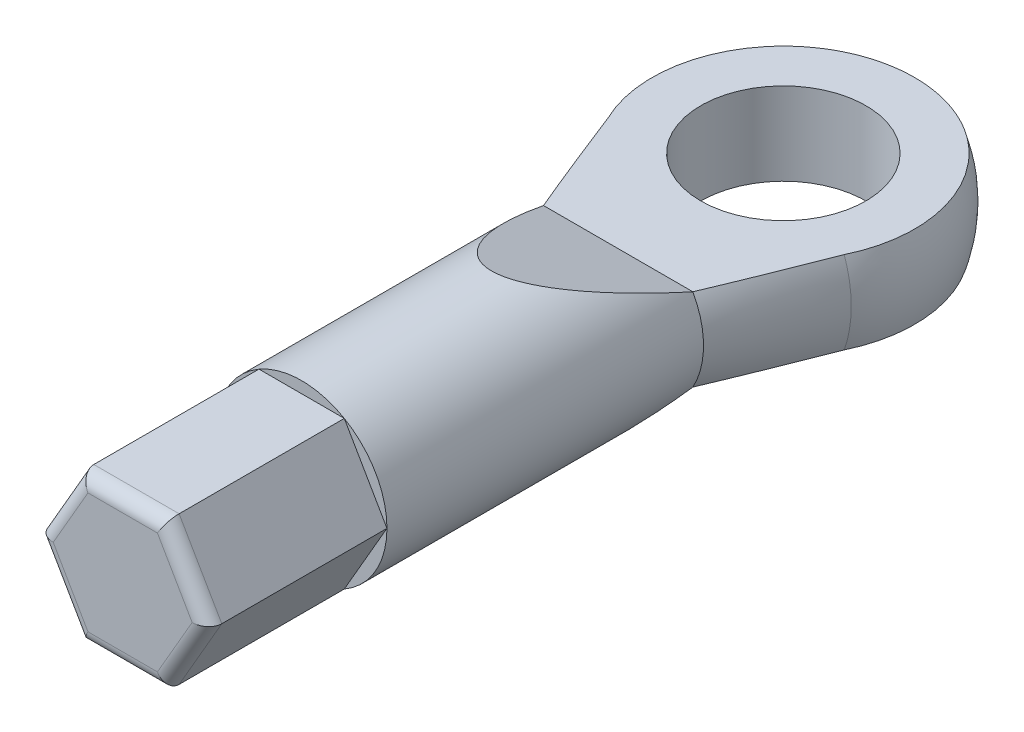
from build123d import *

# Parameters (mm, degrees)
CUT_EXTRUDE2_DEPTH = 6
SKETCH4_OUTSIDE_W  = 18.26
SKETCH4_OUTSIDE_H  = 14.46
CUT_EXTRUDE3_DEPTH = 6.5
FILLET1_R          = 0.5
CUT_EXTRUDE4_START = -1.5
SKETCH5_R          = 3
CUT_EXTRUDE4_DEPTH = 1.5


with BuildPart() as part:
    # Sketch1 → Revolve1 (revolve)
    with BuildSketch(Plane(origin=(0, 0, 0), x_dir=(1, 0, 0), z_dir=(0, 1, 0))):
        with BuildLine():
            ThreePointArc((0, 29), (-4.207271262, 26.701641821), (-4.546615997, 21.919547411))
            Line((-4.546615997, 21.919547411), (-3.1, 18))
            Line((-3.1, 18), (-3.1, 0))
            Line((-3.1, 0), (0, 0))
            Line((0, 0), (0, 29))
        make_face()
    revolve(axis=Axis((0, 0, -29), (0, 0, 1)))

    # Sketch2 → Cut-Extrude2 (cut, symmetric)
    with BuildSketch(Plane(origin=(0, 0, 0), x_dir=(0, 0, -1), z_dir=(1, 0, 0))):
        with BuildLine():
            Line((18, 1.5), (28.769696007, 1.5))
            ThreePointArc((28.769696007, 1.5), (26.031864858, 4.56853644), (21.919547411, 4.546615997))
            Line((21.919547411, 4.546615997), (18, 3.1))
            Line((18, 3.1), (13.400256656, 3.1))
            Line((13.400256656, 3.1), (18, 1.5))
        make_face()
        with BuildLine():
            ThreePointArc((21.919547411, -4.546615997), (26.031864858, -4.56853644), (28.769696007, -1.5))
            Line((28.769696007, -1.5), (18, -1.5))
            Line((18, -1.5), (13.400256656, -3.1))
            Line((13.400256656, -3.1), (18, -3.1))
            Line((18, -3.1), (21.919547411, -4.546615997))
        make_face()
    extrude(amount=CUT_EXTRUDE2_DEPTH, both=True, mode=Mode.SUBTRACT)

    # Sketch4 outside → Cut-Extrude3 (cut)
    with BuildSketch(Plane.XY):
        Rectangle(SKETCH4_OUTSIDE_W, SKETCH4_OUTSIDE_H)
        Polygon((1.55, 2.684678752), (-1.55, 2.684678752), (-3.1, 0), (-1.55, -2.684678752), (1.55, -2.684678752), (3.1, 0), align=None, mode=Mode.SUBTRACT)
    extrude(amount=-CUT_EXTRUDE3_DEPTH, mode=Mode.SUBTRACT)

    # Fillet1
    fillet1_edges = [part.edges().sort_by_distance(p)[0] for p in [
        (2.325, 1.342339376, 0),
        (2.325, -1.342339376, 0),
        (0, -2.684678752, 0),
        (-2.325, -1.342339376, 0),
        (-2.325, 1.342339376, 0),
        (0, 2.684678752, 0),
    ]]
    fillet(fillet1_edges, radius=FILLET1_R)

    # Sketch5 → Cut-Extrude4 (cut, symmetric)
    with BuildSketch(Plane(origin=(0, 1.5, 0), x_dir=(1, 0, 0), z_dir=(0, 1, 0)).offset(CUT_EXTRUDE4_START)):
        with Locations(Location((0, 24, 0), (0, 0, 270))):
            Circle(SKETCH5_R)
    extrude(amount=CUT_EXTRUDE4_DEPTH, both=True, mode=Mode.SUBTRACT)


solid = part.part
